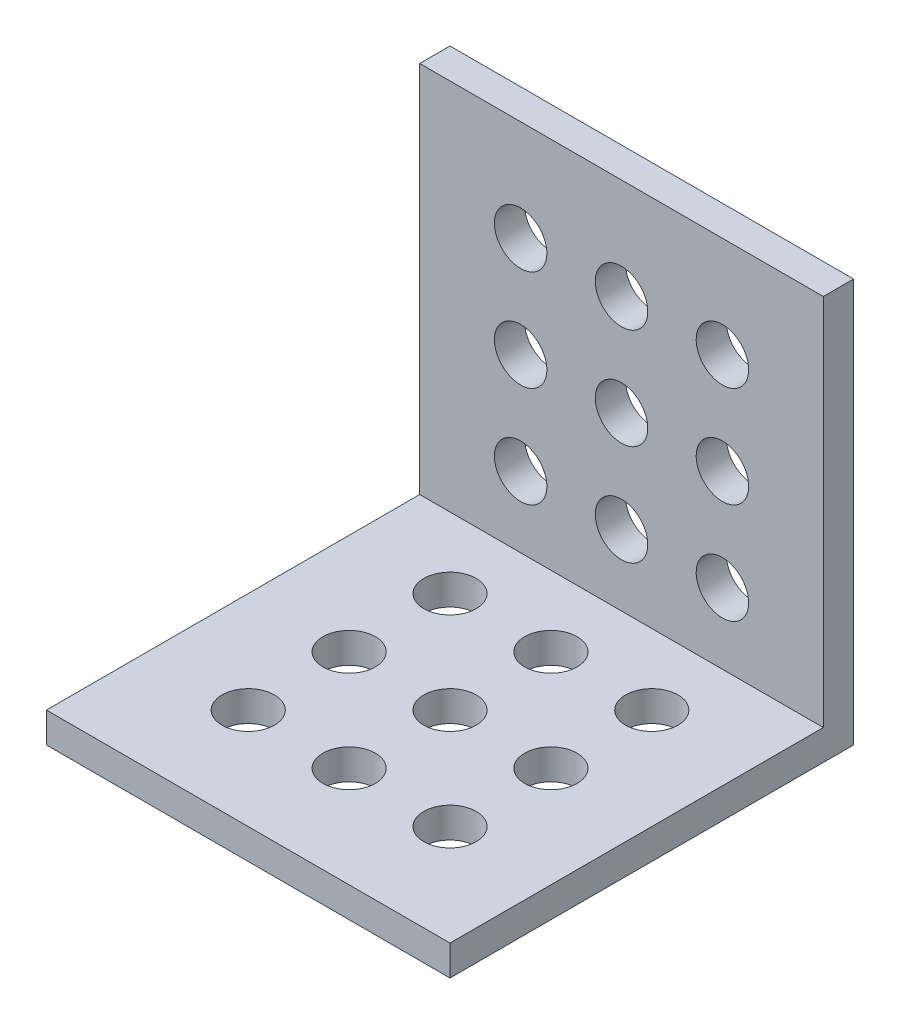
from build123d import *

# Parameters (mm, degrees)
BOSS_EXTRUDE1_DEPTH = 40
SKETCH2_R           = 2.6
CUT_EXTRUDE1_DEPTH  = 4


with BuildPart() as part:
    # Sketch1 → Boss-Extrude1 (new body)
    with BuildSketch(Plane(origin=(0, 0, 0), x_dir=(0, 0, -1), z_dir=(1, 0, 0))):
        Polygon((0, 0), (0, 3), (37, 3), (37, 40), (40, 40), (40, 0), align=None)
    extrude(amount=-BOSS_EXTRUDE1_DEPTH)

    # Sketch2 → Cut-Extrude1 (cut, through all)
    with BuildSketch(Plane(origin=(0, 3, 0), x_dir=(1, 0, 0), z_dir=(0, 1, 0))):
        with Locations((-30, 10)):
            Circle(SKETCH2_R)
        with Locations((-20, 10)):
            Circle(SKETCH2_R)
        with Locations((-10, 10)):
            Circle(SKETCH2_R)
        with Locations((-20, 20)):
            Circle(SKETCH2_R)
        with Locations((-10, 20)):
            Circle(SKETCH2_R)
        with Locations((-20, 30)):
            Circle(SKETCH2_R)
        with Locations((-10, 30)):
            Circle(SKETCH2_R)
        with Locations((-30, 20)):
            Circle(SKETCH2_R)
        with Locations((-30, 30)):
            Circle(SKETCH2_R)
    cut_extrude1 = extrude(amount=-CUT_EXTRUDE1_DEPTH, mode=Mode.SUBTRACT)

    # Mirror1: Cut-Extrude1 across plane
    add(cut_extrude1.mirror(Plane(origin=(0, 20, -20), x_dir=(0, 0.707106781, 0.707106781), z_dir=(0, 0.707106781, -0.707106781))), mode=Mode.SUBTRACT)


solid = part.part
